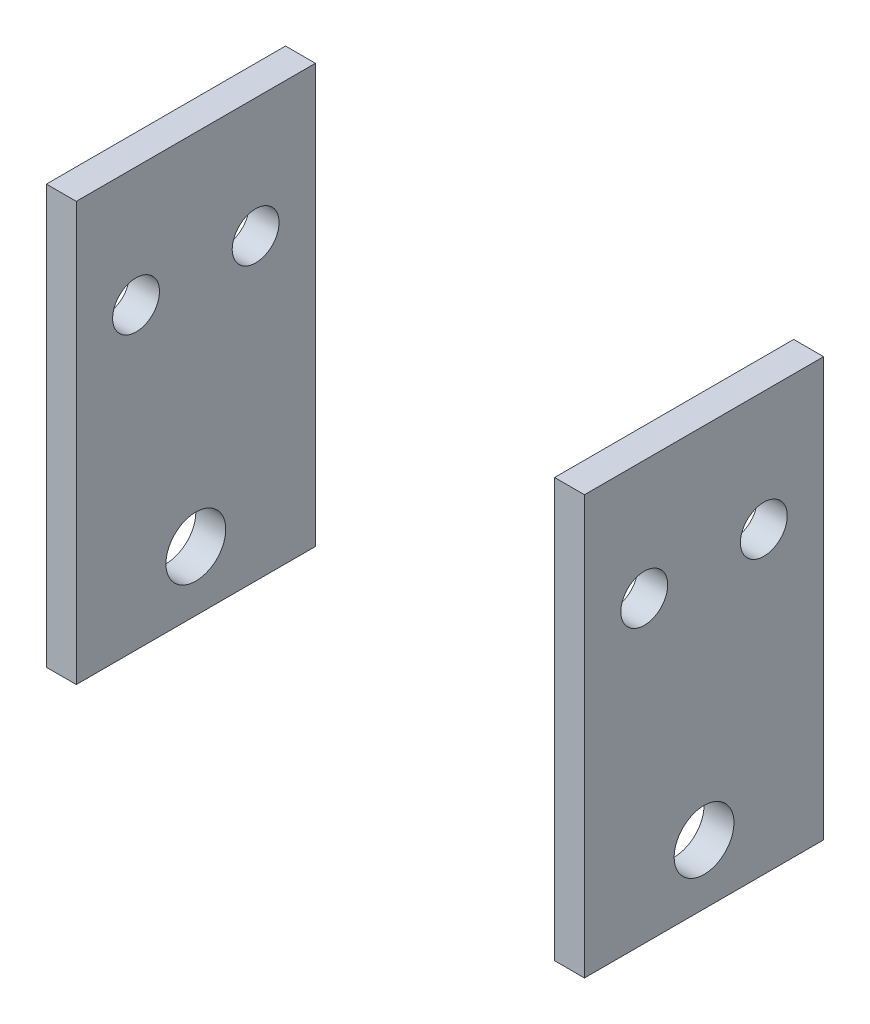
from build123d import *

# Parameters (mm, degrees)
SKETCH1_W             = 3.175
SKETCH1_H             = 68.663112769
BOSS_EXTRUDE1_DEPTH   = 25.4
BOSS_EXTRUDE1_2_DEPTH = 25.4
SKETCH2_R             = 3.175
SKETCH2_R_2           = 2.4892
CUT_EXTRUDE1_DEPTH    = 58.15
SKETCH3_W             = 25.4
SKETCH3_H             = 9.525
SKETCH3_H_2           = 14.688112769
CUT_EXTRUDE3_DEPTH    = 58.15


with BuildPart() as part:
    # Sketch1 → Boss-Extrude1 (new body)
    with BuildSketch(Plane.XY):
        with Locations((71.4375, 22.818443616)):
            Rectangle(SKETCH1_W, SKETCH1_H)
    extrude(amount=BOSS_EXTRUDE1_DEPTH)


with BuildPart() as body_2:
    # Sketch1 → Boss-Extrude1 2 (new body)
    with BuildSketch(Plane.XY):
        with Locations((17.4625, 22.818443616)):
            Rectangle(SKETCH1_W, SKETCH1_H)
    extrude(amount=BOSS_EXTRUDE1_2_DEPTH)


with BuildPart() as cut_extrude1_tool:
    # Sketch2 → Cut-Extrude1 (new body, through all)
    with BuildSketch(Plane(origin=(73.025, 0, 0), x_dir=(0, 0, -1), z_dir=(1, 0, 0))):
        with Locations((-12.7, 4.361887231)):
            Circle(SKETCH2_R)
        with Locations((-19.05, 29.761887231)):
            Circle(SKETCH2_R_2)
        with Locations((-6.35, 29.761887231)):
            Circle(SKETCH2_R_2)
    extrude(amount=-CUT_EXTRUDE1_DEPTH)


with BuildPart() as part_1:
    add(part.part)

    # Cut-Extrude1: cut by cut_extrude1_tool
    add(cut_extrude1_tool.part, mode=Mode.SUBTRACT)


with BuildPart() as body_2_1:
    add(body_2.part)

    # Cut-Extrude1: cut by cut_extrude1_tool
    add(cut_extrude1_tool.part, mode=Mode.SUBTRACT)


with BuildPart() as cut_extrude3_tool:
    # Sketch3 → Cut-Extrude3 (new body, through all)
    with BuildSketch(Plane(origin=(73.025, 0, 0), x_dir=(0, 0, -1), z_dir=(1, 0, 0))):
        with Locations((-12.7, -6.750612769)):
            Rectangle(SKETCH3_W, SKETCH3_H)
        with Locations((-12.7, 49.805943616)):
            Rectangle(SKETCH3_W, SKETCH3_H_2)
    extrude(amount=-CUT_EXTRUDE3_DEPTH)


with BuildPart() as part_2:
    add(part_1.part)

    # Cut-Extrude3: cut by cut_extrude3_tool
    add(cut_extrude3_tool.part, mode=Mode.SUBTRACT)


with BuildPart() as body_2_2:
    add(body_2_1.part)

    # Cut-Extrude3: cut by cut_extrude3_tool
    add(cut_extrude3_tool.part, mode=Mode.SUBTRACT)


solid = Compound([part_2.part, body_2_2.part])
